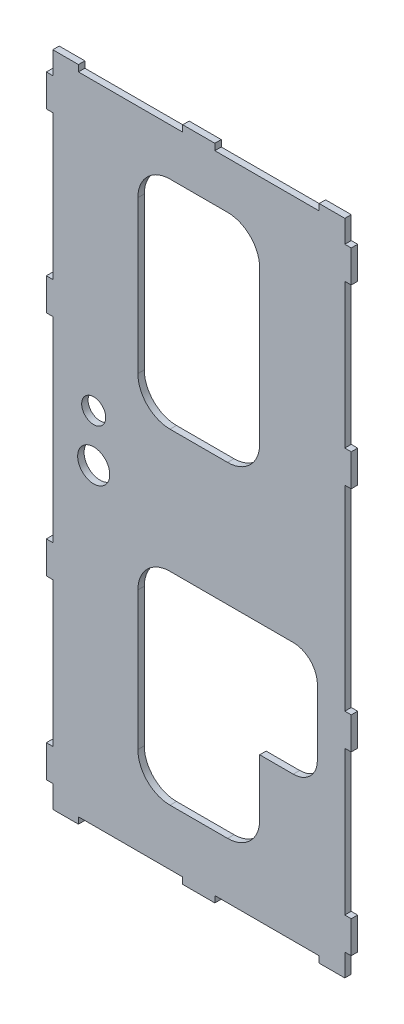
from build123d import *

# Parameters (mm, degrees)
BOSS_EXTRUDE2_DEPTH = 4
CUT_EXTRUDE1_DEPTH  = 10
SKETCH3_R           = 7.5
SKETCH3_R_2         = 10
CUT_EXTRUDE2_DEPTH  = 10


with BuildPart() as part:
    # Sketch1 → Boss-Extrude2 (new body)
    with BuildSketch(Plane.XY):
        Polygon((-75, -201), (-10, -201), (-10, -205), (10, -205), (10, -201), (75, -201), (75, -205), (91, -205), (91, -191), (95, -191), (95, -171), (91, -171), (91, -81), (95, -81), (95, -61), (91, -61), (91, 61), (95, 61), (95, 81), (91, 81), (91, 171), (95, 171), (95, 191), (91, 191), (91, 205), (75, 205), (75, 201), (10, 201), (10, 205), (-10, 205), (-10, 201), (-75, 201), (-75, 205), (-91, 205), (-91, 191), (-95, 191), (-95, 171), (-91, 171), (-91, 81), (-95, 81), (-95, 61), (-91, 61), (-91, -61), (-95, -61), (-95, -81), (-91, -81), (-91, -171), (-95, -171), (-95, -191), (-91, -191), (-91, -205), (-75, -205), align=None)
        with BuildLine():
            Line((-17.949055326, 171.697819396), (17.949055326, 171.697819396))
            ThreePointArc((17.949055326, 171.697819396), (32.09119095, 165.83995502), (37.949055326, 151.697819396))
            Line((37.949055326, 151.697819396), (37.949055326, 56.741742537))
            ThreePointArc((37.949055326, 56.741742537), (32.09119095, 42.599606914), (17.949055326, 36.741742537))
            Line((17.949055326, 36.741742537), (-17.949055326, 36.741742537))
            ThreePointArc((-17.949055326, 36.741742537), (-32.09119095, 42.599606914), (-37.949055326, 56.741742537))
            Line((-37.949055326, 56.741742537), (-37.949055326, 151.697819396))
            ThreePointArc((-37.949055326, 151.697819396), (-32.09119095, 165.83995502), (-17.949055326, 171.697819396))
        make_face(mode=Mode.SUBTRACT)
        with BuildLine():
            Line((-17.949055326, -166.180135652), (17.949055326, -166.180135652))
            ThreePointArc((17.949055326, -166.180135652), (32.09119095, -160.322271276), (37.949055326, -146.180135652))
            Line((37.949055326, -146.180135652), (37.949055326, -60))
            ThreePointArc((37.949055326, -60), (32.09119095, -45.857864376), (17.949055326, -40))
            Line((17.949055326, -40), (-17.949055326, -40))
            ThreePointArc((-17.949055326, -40), (-32.09119095, -45.857864376), (-37.949055326, -60))
            Line((-37.949055326, -60), (-37.949055326, -146.180135652))
            ThreePointArc((-37.949055326, -146.180135652), (-32.09119095, -160.322271276), (-17.949055326, -166.180135652))
        make_face(mode=Mode.SUBTRACT)
    extrude(amount=BOSS_EXTRUDE2_DEPTH)

    # Sketch2 → Cut-Extrude1 (cut)
    with BuildSketch(Plane.XY.offset(4)):
        with BuildLine():
            Line((0, -40), (58.886613453, -40))
            ThreePointArc((58.886613453, -40), (69.49321517, -44.393398282), (73.886613453, -55))
            Line((73.886613453, -55), (73.886613453, -96.0450181))
            ThreePointArc((73.886613453, -96.0450181), (69.49321517, -106.651619817), (58.886613453, -111.0450181))
            Line((58.886613453, -111.0450181), (0, -111.0450181))
            Line((0, -111.0450181), (0, -40))
        make_face()
    extrude(amount=-CUT_EXTRUDE1_DEPTH, mode=Mode.SUBTRACT)

    # Sketch3 → Cut-Extrude2 (cut)
    with BuildSketch(Plane.XY.offset(4)):
        with Locations((-65.497286905, 22.916669932)):
            Circle(SKETCH3_R)
        with Locations((-65.497286905, -6.583495202)):
            Circle(SKETCH3_R_2)
    extrude(amount=-CUT_EXTRUDE2_DEPTH, mode=Mode.SUBTRACT)


solid = part.part
